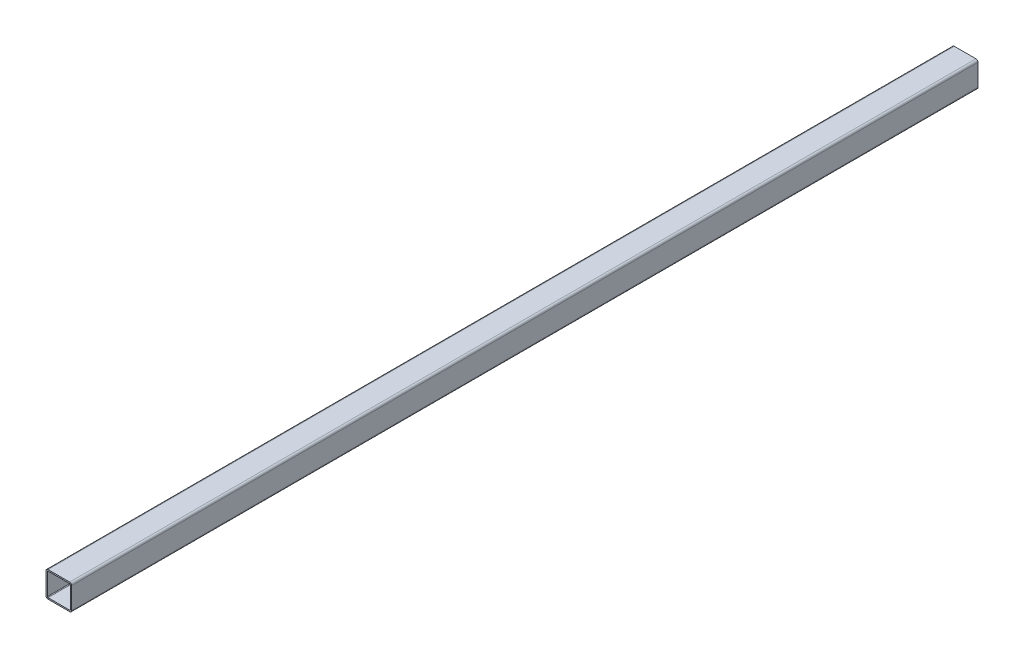
from build123d import *

# Parameters (mm, degrees)
BOSS_EXTRUDE1_DEPTH = 670


with BuildPart() as part:
    # Sketch1 → Boss-Extrude1 (new body)
    with BuildSketch(Plane.XY):
        with BuildLine():
            Line((-8, -9.5), (8, -9.5))
            ThreePointArc((8, -9.5), (9.060660172, -9.060660172), (9.5, -8))
            Line((9.5, -8), (9.5, 8))
            ThreePointArc((9.5, 8), (9.060660172, 9.060660172), (8, 9.5))
            Line((8, 9.5), (-8, 9.5))
            ThreePointArc((-8, 9.5), (-9.060660172, 9.060660172), (-9.5, 8))
            Line((-9.5, 8), (-9.5, -8))
            ThreePointArc((-9.5, -8), (-9.060660172, -9.060660172), (-8, -9.5))
        make_face()
        with BuildLine():
            Line((-8, 8.5), (8, 8.5))
            ThreePointArc((8, 8.5), (8.353553391, 8.353553391), (8.5, 8))
            Line((8.5, 8), (8.5, -8))
            ThreePointArc((8.5, -8), (8.353553391, -8.353553391), (8, -8.5))
            Line((8, -8.5), (-8, -8.5))
            ThreePointArc((-8, -8.5), (-8.353553391, -8.353553391), (-8.5, -8))
            Line((-8.5, -8), (-8.5, 8))
            ThreePointArc((-8.5, 8), (-8.353553391, 8.353553391), (-8, 8.5))
        make_face(mode=Mode.SUBTRACT)
    extrude(amount=BOSS_EXTRUDE1_DEPTH)


solid = part.part
